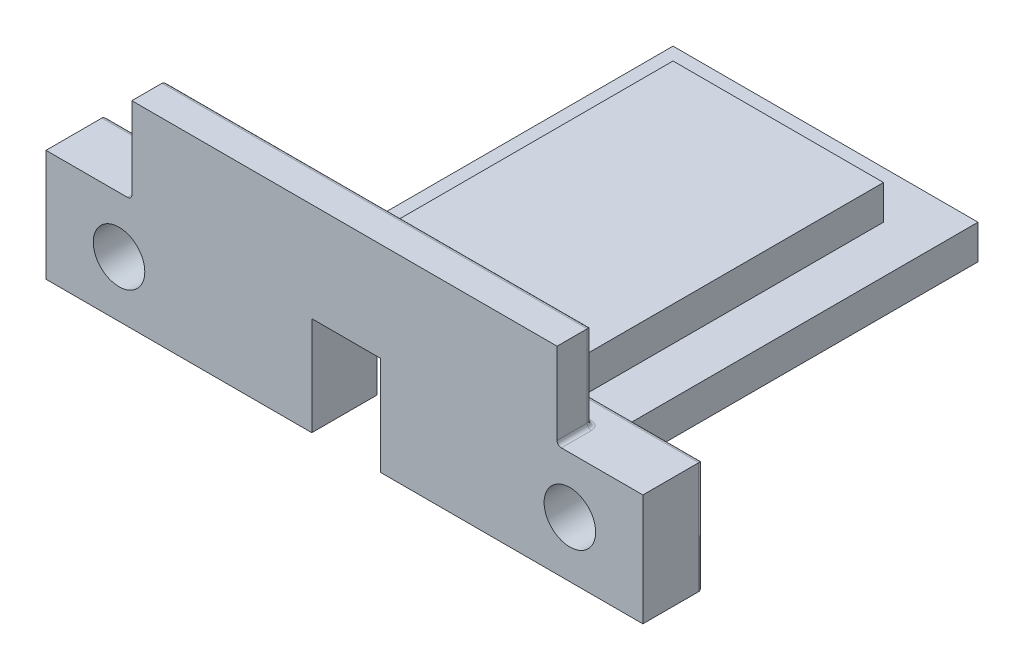
from build123d import *

# Parameters (mm, degrees)
ESQUISSE1_W             = 35.5
ESQUISSE1_H             = 56
ESQUISSE1_W_2           = 20.1
ESQUISSE1_H_2           = 40.9
BOSS_EXTRU_1_DEPTH      = 4
BOSS_EXTRU_2_DEPTH      = 4
BOSS_EXTRU_5_DEPTH      = 4
ESQUISSE10_W            = 17
ESQUISSE10_H            = 13
BOSS_EXTRU_6_DEPTH      = 7
ESQUISSE11_R            = 3
ENL_V_MAT_EXTRU_1_DEPTH = 7
CONG_1_R                = 0.5
ESQUISSE12_W            = 8
ESQUISSE12_H            = 10.6
ENL_V_MAT_EXTRU_2_DEPTH = 11.5


with BuildPart() as part:
    # Esquisse1 → Boss.-Extru.1 (new body)
    with BuildSketch(Plane(origin=(0, 0, 0), x_dir=(1, 0, 0), z_dir=(0, 1, 0))):
        with Locations((-6.25, -0.5)):
            Rectangle(ESQUISSE1_W, ESQUISSE1_H)
        with Locations((-6.05, -0.45)):
            Rectangle(ESQUISSE1_W_2, ESQUISSE1_H_2, mode=Mode.SUBTRACT)
    extrude(amount=BOSS_EXTRU_1_DEPTH)

    # Esquisse5 → Boss.-Extru.2 (add)
    with BuildSketch(Plane.XY.offset(28.5)):
        Polygon((-6.25, 8), (-6.25, 4), (-6.25, 0), (11.5, 0), (11.5, 13), (18.5, 13), (18.5, 18), (18.5, 23), (-6.25, 23), (-6.25, 18), align=None)
    boss_extru_2 = extrude(amount=-BOSS_EXTRU_2_DEPTH)

    # Symétrie1: Boss.-Extru.2 across plane
    add(boss_extru_2.mirror(Plane(origin=(-6.25, 4, 24.5), x_dir=(0, 0, 1), z_dir=(-1, 0, 0))))

    # Esquisse9 → Boss.-Extru.5 (add)
    with BuildSketch(Plane(origin=(0, 4, 0), x_dir=(-1, 0, 0), z_dir=(0, -1, 0))):
        Polygon((18.5, -25.5), (18.5, -23), (18.5, 20), (18.5, 22), (-6, 22), (-6, -25.5), align=None)
    extrude(amount=-BOSS_EXTRU_5_DEPTH)

    # Esquisse10 → Boss.-Extru.6 (add)
    with BuildSketch(Plane.XY.offset(28.5)):
        with Locations((19.990927164, 6.5)):
            Rectangle(ESQUISSE10_W, ESQUISSE10_H)
    boss_extru_6 = extrude(amount=-BOSS_EXTRU_6_DEPTH)

    # Symétrie2: Boss.-Extru.6 across plane
    add(boss_extru_6.mirror(Plane(origin=(-6.25, 0, 0), x_dir=(0, 0, 1), z_dir=(1, 0, 0))))

    # Esquisse11 → Enlèv. mat.-Extru.1 (cut)
    with BuildSketch(Plane(origin=(0, 0, 21.5), x_dir=(-1, 0, 0), z_dir=(0, 0, -1))):
        with Locations((-19.990927164, 6.5)):
            Circle(ESQUISSE11_R)
    enl_v_mat_extru_1 = extrude(amount=-ENL_V_MAT_EXTRU_1_DEPTH, mode=Mode.SUBTRACT)

    # Symétrie3: Enlèv. mat.-Extru.1 across plane
    add(enl_v_mat_extru_1.mirror(Plane(origin=(-6.25, 0, 0), x_dir=(0, 0, 1), z_dir=(1, 0, 0))), mode=Mode.SUBTRACT)

    # Congé1
    cong_1_edges = [part.edges().sort_by_distance(p)[0] for p in [
        (19.995463582, 0, 21.5),
        (11.490927164, 8.5, 24.5),
        (19.990927164, 13, 21.5),
        (28.490927164, 6.5, 21.5),
        (-21.245463582, 4, 24.5),
        (-23.990927164, 8.5, 24.5),
        (-32.495463582, 0, 21.5),
        (-40.990927164, 6.5, 21.5),
        (-32.490927164, 13, 21.5),
        (14.995463582, 13, 24.5),
        (18.5, 13, 26.5),
        (-6.25, 23, 24.5),
        (18.5, 18, 24.5),
        (-31, 13, 26.5),
        (-27.495463582, 13, 24.5),
        (-31, 18, 24.5),
        (8.745463582, 4, 24.5),
        (-6.25, 8, 24.5),
        (6, 6, 24.5),
        (-18.5, 6, 24.5),
    ]]
    fillet(cong_1_edges, radius=CONG_1_R)

    # Esquisse12 → Enlèv. mat.-Extru.2 (cut)
    with BuildSketch(Plane.XZ):
        with Locations((-6.05, 23.2)):
            Rectangle(ESQUISSE12_W, ESQUISSE12_H)
    extrude(amount=-ENL_V_MAT_EXTRU_2_DEPTH, mode=Mode.SUBTRACT)


solid = part.part
